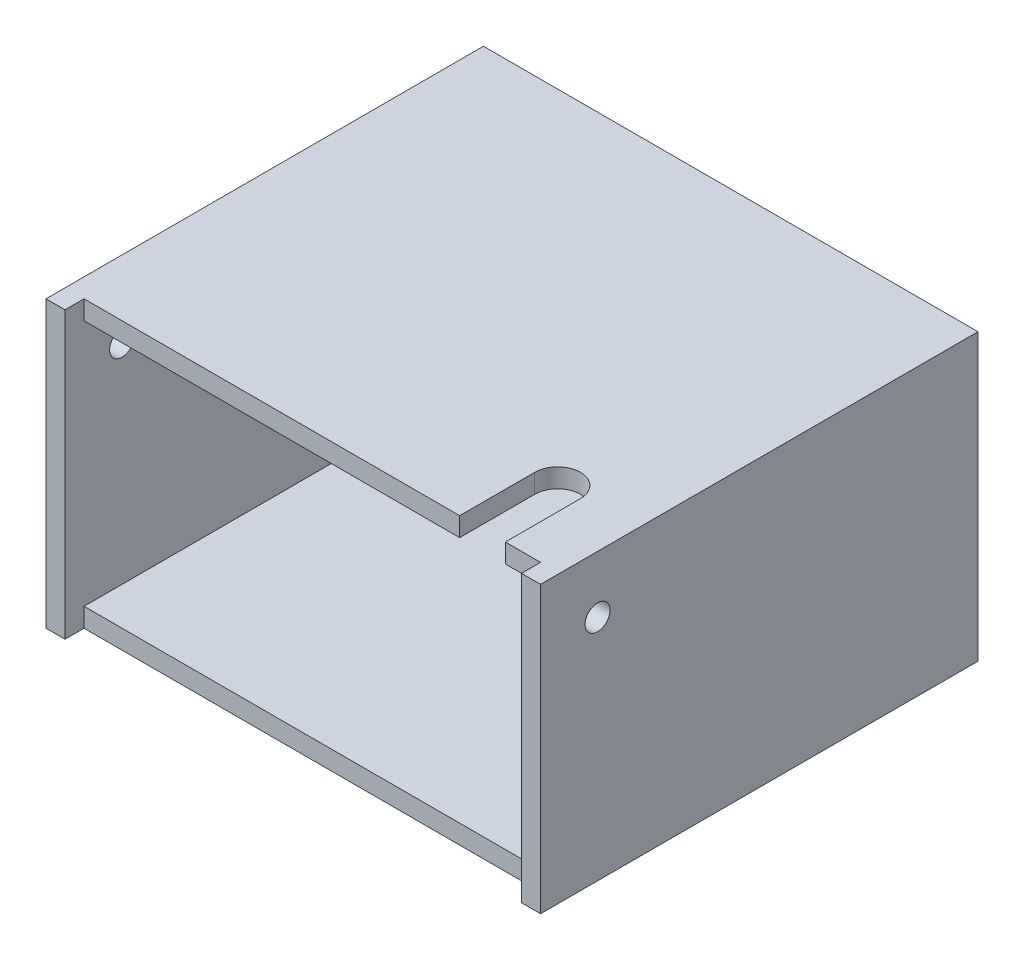
from build123d import *

# Parameters (mm, degrees)
SKETCH1_W               = 76.2
SKETCH1_H               = 69.85
BOSS_EXTRUDE1_DEPTH     = 41.275
SHELL2_T                = 3.175
SKETCH2_W               = 76.2
SKETCH2_H               = 3.175
CUT_EXTRUDE1_DEPTH      = 74.643575755
CUT_EXTRUDE1_DEPTH_BACK = 74.643575755
CUT_EXTRUDE2_REACH      = 75.644
SKETCH4_R               = 2.0828
CUT_EXTRUDE3_DEPTH      = 3.175
SKETCH5_R               = 2.0828
CUT_EXTRUDE4_DEPTH      = 99.629626001
CUT_EXTRUDE4_DEPTH_BACK = 99.629626001


with BuildPart() as part:
    # Sketch1 → Boss-Extrude1 (new body)
    with BuildSketch(Plane(origin=(0, 0, 0), x_dir=(1, 0, 0), z_dir=(0, 1, 0))):
        Rectangle(SKETCH1_W, SKETCH1_H)
    extrude(amount=BOSS_EXTRUDE1_DEPTH)

    # Shell2
    shell2_openings = [part.faces().sort_by_distance(p)[0] for p in [
        (0, 20.6375, 34.925),
    ]]
    offset(amount=SHELL2_T, openings=shell2_openings, kind=Kind.INTERSECTION)

    # Sketch2 → Cut-Extrude1 (cut, two sides)
    with BuildSketch(Plane(origin=(0, 44.45, 0), x_dir=(1, 0, 0), z_dir=(0, 1, 0))) as cut_extrude1_sk:
        with Locations((0, -33.3375)):
            Rectangle(SKETCH2_W, SKETCH2_H)
    extrude(amount=CUT_EXTRUDE1_DEPTH, mode=Mode.SUBTRACT)
    extrude(cut_extrude1_sk.sketch, amount=-CUT_EXTRUDE1_DEPTH_BACK, mode=Mode.SUBTRACT)

    # Sketch3 → Cut-Extrude2 (cut, up to next)
    with BuildSketch(Plane(origin=(0, 44.45, 0), x_dir=(1, 0, 0), z_dir=(0, 1, 0)), mode=Mode.PRIVATE) as cut_extrude2_sk1:
        with BuildLine():
            Line((24.5999, -19.2151), (24.5999, -31.75))
            Line((24.5999, -31.75), (32.2199, -31.75))
            Line((32.2199, -31.75), (32.2199, -19.2151))
            ThreePointArc((32.2199, -19.2151), (28.4099, -15.4051), (24.5999, -19.2151))
        make_face()
    cut_extrude2_tool1 = extrude(cut_extrude2_sk1.sketch, amount=-CUT_EXTRUDE2_REACH, mode=Mode.PRIVATE) & part.part
    add(cut_extrude2_tool1.solids().sort_by_distance((28.4099, 44.45, 23.96308))[0], mode=Mode.SUBTRACT)

    # Sketch4 → Cut-Extrude3 (cut)
    with BuildSketch(Plane.XY.offset(-34.925)):
        with Locations((0, 9.525)):
            Circle(SKETCH4_R)
    extrude(amount=-CUT_EXTRUDE3_DEPTH, mode=Mode.SUBTRACT)

    # Sketch5 → Cut-Extrude4 (cut, two sides)
    with BuildSketch(Plane.ZY.offset(-38.1)) as cut_extrude4_sk:
        with Locations((25.4, 34.925)):
            Circle(SKETCH5_R)
    extrude(amount=CUT_EXTRUDE4_DEPTH, mode=Mode.SUBTRACT)
    extrude(cut_extrude4_sk.sketch, amount=-CUT_EXTRUDE4_DEPTH_BACK, mode=Mode.SUBTRACT)


solid = part.part
